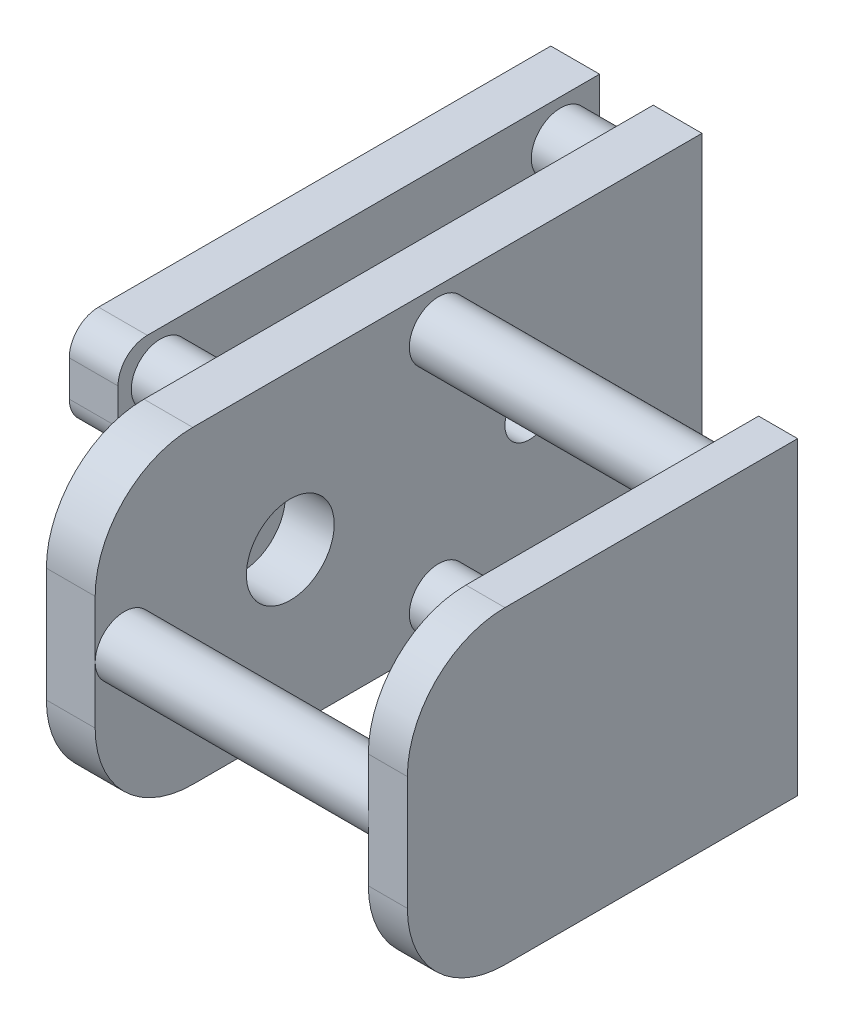
from build123d import *

# Parameters (mm, degrees)
SKETCH_1_R      = 4.5
SKETCH_1_R_2    = 2.5
EXTRUDE_1_DEPTH = 5
SKETCH_2_R      = 3
EXTRUDE_2_DEPTH = 28
EXTRUDE_3_DEPTH = 4
SKETCH_5_R      = 3
EXTRUDE_4_DEPTH = 5.5
EXTRUDE_6_DEPTH = 5
SKETCH_7_R      = 1.6
EXTRUDE_7_DEPTH = 1.4


with BuildPart() as part:
    # 草图1 → 凸台-拉伸1 (new body)
    with BuildSketch(Plane(origin=(0, 0, 0), x_dir=(0, 0, -1), z_dir=(1, 0, 0))):
        with BuildLine():
            Line((31.1, -15.85), (-21.1, -15.85))
            ThreePointArc((-21.1, -15.85), (-28.171067812, -12.921067812), (-31.1, -5.85))
            Line((-31.1, -5.85), (-31.1, 5.85))
            ThreePointArc((-31.1, 5.85), (-28.171067812, 12.921067812), (-21.1, 15.85))
            Line((-21.1, 15.85), (31.1, 15.85))
            Line((31.1, 15.85), (31.1, -15.85))
        make_face()
        with Locations((-11.1, 0)):
            Circle(SKETCH_1_R, mode=Mode.SUBTRACT)
        with Locations((13.4, 0)):
            Circle(SKETCH_1_R_2, mode=Mode.SUBTRACT)
    extrude(amount=EXTRUDE_1_DEPTH)

    # 草图2 → 凸台-拉伸2 (add)
    with BuildSketch(Plane(origin=(5, 0, 0), x_dir=(0, 0, -1), z_dir=(1, 0, 0))):
        with Locations((-28.1, 0)):
            Circle(SKETCH_2_R)
        with Locations((4.1, 11.85)):
            Circle(SKETCH_2_R)
        with Locations((4.1, -11.85)):
            Circle(SKETCH_2_R)
    extrude(amount=EXTRUDE_2_DEPTH)

    # 草图3 → 凸台-拉伸3 (add)
    with BuildSketch(Plane(origin=(33, 0, 0), x_dir=(0, 0, -1), z_dir=(1, 0, 0))):
        with BuildLine():
            Line((8.9, 15.85), (-21.1, 15.85))
            ThreePointArc((-21.1, 15.85), (-28.171067812, 12.921067812), (-31.1, 5.85))
            Line((-31.1, 5.85), (-31.1, 0))
            Line((-31.1, 0), (-31.1, -5.85))
            ThreePointArc((-31.1, -5.85), (-28.171067812, -12.921067812), (-21.1, -15.85))
            Line((-21.1, -15.85), (8.9, -15.85))
            Line((8.9, -15.85), (8.9, 15.85))
        make_face()
    extrude(amount=EXTRUDE_3_DEPTH)

    # 草图5 → 凸台-拉伸4 (add)
    with BuildSketch(Plane.ZY):
        with Locations((-27.1, 11.85)):
            Circle(SKETCH_5_R)
        with Locations((-27.1, -11.978090594)):
            Circle(SKETCH_5_R)
        with Locations((13.9, 11.85)):
            Circle(SKETCH_5_R)
        with Locations((13.9, -11.978090594)):
            Circle(SKETCH_5_R)
    extrude(amount=EXTRUDE_4_DEPTH)

    # 草图6 → 凸台-拉伸6 (add)
    with BuildSketch(Plane.ZY.offset(5.5)):
        with BuildLine():
            Line((15.255672946, -15.85), (-31.1, -15.85))
            Line((-31.1, -15.85), (-31.1, 15.85))
            Line((-31.1, 15.85), (15.255672946, 15.85))
            ThreePointArc((15.255672946, 15.85), (17.376993289, 14.971320344), (18.255672946, 12.85))
            Line((18.255672946, 12.85), (18.255672946, 9.183659284))
            ThreePointArc((18.255672946, 9.183659284), (17.376993289, 7.062338941), (15.255672946, 6.183659284))
            Line((15.255672946, 6.183659284), (8.696116264, 6.183659284))
            ThreePointArc((8.696116264, 6.183659284), (6.574795921, 5.304979628), (5.696116264, 3.183659284))
            Line((5.696116264, 3.183659284), (5.696116264, -3.183659284))
            ThreePointArc((5.696116264, -3.183659284), (6.574795921, -5.304979628), (8.696116264, -6.183659284))
            Line((8.696116264, -6.183659284), (15.255672946, -6.183659284))
            ThreePointArc((15.255672946, -6.183659284), (17.376993289, -7.062338941), (18.255672946, -9.183659284))
            Line((18.255672946, -9.183659284), (18.255672946, -12.85))
            ThreePointArc((18.255672946, -12.85), (17.376993289, -14.971320344), (15.255672946, -15.85))
        make_face()
    extrude(amount=EXTRUDE_6_DEPTH)

    # 草图7 → 凸台-拉伸7 (add)
    with BuildSketch(Plane.XZ.offset(15.85)):
        with Locations((2.5, 10.7)):
            Circle(SKETCH_7_R)
        with Locations((2.5, -23.1)):
            Circle(SKETCH_7_R)
    extrude(amount=EXTRUDE_7_DEPTH)


solid = part.part
